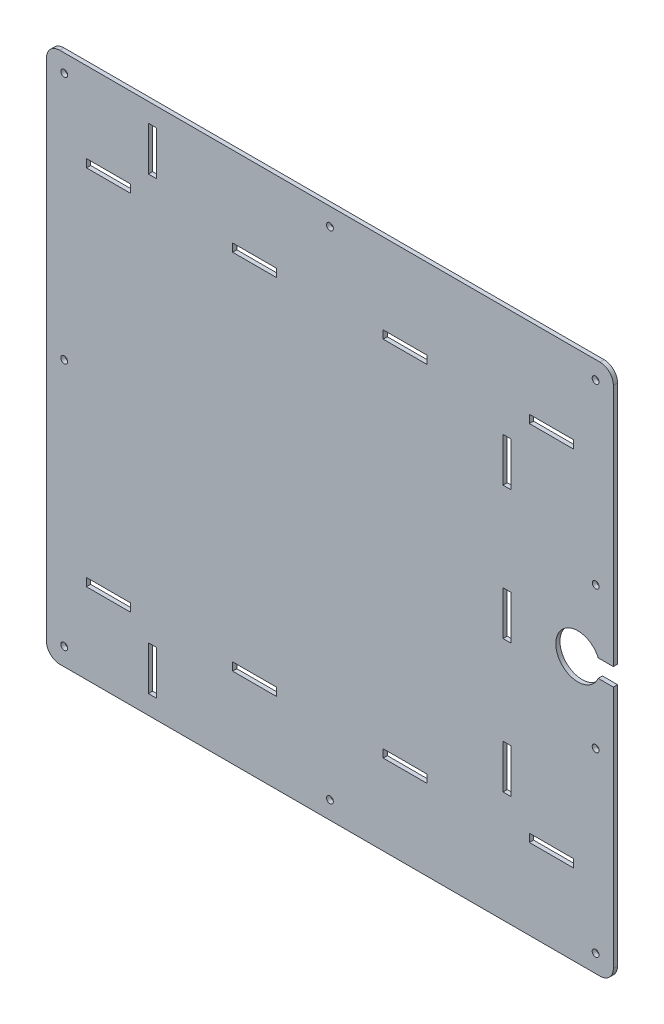
from build123d import *

# Parameters (mm, degrees)
BOSS_EXTRUDE1_DEPTH                   = 3
F_10_0_1935_DIAMETER_HOLE2_AT_2_COUNT = 2
F_10_0_1935_DIAMETER_HOLE2_AT_2_PITCH = 260.668884466
F_10_0_1935_DIAMETER_HOLE1_D          = 4.9149
F_10_0_1935_DIAMETER_HOLE1_DEPTH      = 76.2
F_10_0_1935_DIAMETER_HOLE1_TIP        = 1.476584928
SKETCH9_W                             = 31.5468
SKETCH9_H                             = 5.7658
SKETCH9_W_2                           = 5.7658
SKETCH9_H_2                           = 31.5468
CUT_EXTRUDE1_DEPTH                    = 4


with BuildPart() as part:
    # Sketch1 → Boss-Extrude1 (new body)
    with BuildSketch(Plane.XY):
        with BuildLine():
            Line((-135.866260139, -66.675), (-135.866260139, -314.579))
            Line((-135.866260139, -314.579), (-135.866260139, -371.729))
            ThreePointArc((-135.866260139, -371.729), (-133.07645223, -378.464192091), (-126.341260139, -381.254))
            Line((-126.341260139, -381.254), (261.008739861, -381.254))
            ThreePointArc((261.008739861, -381.254), (267.743931952, -378.464192091), (270.533739861, -371.729))
            Line((270.533739861, -371.729), (270.533739861, -298.704))
            Line((270.533739861, -298.704), (270.533739861, -196.977))
            Line((270.533739861, -196.977), (259.683417693, -196.977))
            ThreePointArc((259.683417693, -196.977), (229.258739861, -190.627), (259.683417693, -184.277))
            Line((259.683417693, -184.277), (270.533739861, -184.277))
            Line((270.533739861, -184.277), (270.533739861, -82.55))
            Line((270.533739861, -82.55), (270.533739861, -9.525))
            ThreePointArc((270.533739861, -9.525), (267.743931952, -2.789807909), (261.008739861, 0))
            Line((261.008739861, 0), (-126.341260139, 0))
            ThreePointArc((-126.341260139, 0), (-133.07645223, -2.789807909), (-135.866260139, -9.525))
            Line((-135.866260139, -9.525), (-135.866260139, -66.675))
        make_face()
    extrude(amount=BOSS_EXTRUDE1_DEPTH)

    # Sketch2 → #10 (0.1935) Diameter Hole3 (revolve, cut)
    with BuildSketch(Plane(origin=(-123.166260139, -12.7, 3), x_dir=(0, -1, 0), z_dir=(1, 0, 0))):
        Polygon((0, 0), (0, 77.676584928), (2.45745, 76.2), (2.45745, 0), align=None)
    f_10_0_1935_diameter_hole3 = revolve(axis=Axis((-123.166260139, -12.7, 9.35), (0, 0, -1)), mode=Mode.SUBTRACT)

    # Sketch7 → #10 (0.1935) Diameter Hole2 (revolve, cut)
    with BuildSketch(Plane(origin=(67.333739861, -12.7, 0), x_dir=(0, 1, 0), z_dir=(1, 0, 0))):
        Polygon((0, 0), (0, 77.676584928), (2.45745, 76.2), (2.45745, 0), align=None)
    f_10_0_1935_diameter_hole2 = revolve(axis=Axis((67.333739861, -12.7, -6.35), (0, 0, 1)), mode=Mode.SUBTRACT)

    # #10 (0.1935) Diameter Hole2 at 2: #10 (0.1935) Diameter Hole2 ×2
    with Locations(*[Vector(-0.730812196, -0.682578591, 0) * (i * F_10_0_1935_DIAMETER_HOLE2_AT_2_PITCH) for i in range(1, F_10_0_1935_DIAMETER_HOLE2_AT_2_COUNT)]):
        add(f_10_0_1935_diameter_hole2, mode=Mode.SUBTRACT)

    # Mirror1: #10 (0.1935) Diameter Hole3 across plane
    add(f_10_0_1935_diameter_hole3.mirror(Plane.ZY.offset(-67.333739861)), mode=Mode.SUBTRACT)

    # Mirror2: #10 (0.1935) Diameter Hole3, #10 (0.1935) Diameter Hole2 across plane
    add(f_10_0_1935_diameter_hole3.mirror(Plane.ZX.offset(-190.627)), mode=Mode.SUBTRACT)
    add(f_10_0_1935_diameter_hole2.mirror(Plane.ZX.offset(-190.627)), mode=Mode.SUBTRACT)

    # Mirror2 copy 1 sketch → Mirror2 copy 1 (revolve, cut)
    with BuildSketch(Plane(origin=(257.833739861, -368.554, 3), x_dir=(0, 1, 0), z_dir=(-1, 0, 0))):
        Polygon((0, 0), (0, 77.676584928), (2.45745, 76.2), (2.45745, 0), align=None)
    revolve(axis=Axis((257.833739861, -368.554, 9.35), (0, 0, -1)), mode=Mode.SUBTRACT)

    # Mirror2 copy 2 sketch → Mirror2 copy 2 (revolve, cut)
    with BuildSketch(Plane(origin=(-123.166260139, -190.627, 0), x_dir=(0, -1, 0), z_dir=(1, 0, 0))):
        Polygon((0, 0), (0, -77.676584928), (2.45745, -76.2), (2.45745, 0), align=None)
    revolve(axis=Axis((-123.166260139, -190.627, -6.35), (0, 0, -1)), mode=Mode.SUBTRACT)

    # #10 (0.1935) Diameter Hole1
    with Locations(Plane(origin=(257.833739861, -241.426988864, 0), x_dir=(-1, 0, 0), z_dir=(0, 0, -1))):
        with Locations((0, 0), (-0.067272713, 101.599977728)):
            Hole(F_10_0_1935_DIAMETER_HOLE1_D / 2, depth=F_10_0_1935_DIAMETER_HOLE1_DEPTH)
            with Locations((0, 0, -(F_10_0_1935_DIAMETER_HOLE1_DEPTH + F_10_0_1935_DIAMETER_HOLE1_TIP / 2))):  # 118° drill point
                Cone(0, F_10_0_1935_DIAMETER_HOLE1_D / 2, F_10_0_1935_DIAMETER_HOLE1_TIP, mode=Mode.SUBTRACT)

    # Sketch9 → Cut-Extrude1 (cut, through all)
    with BuildSketch(Plane(origin=(0, 0, 0), x_dir=(-1, 0, 0), z_dir=(0, 0, -1))):
        with Locations((-121.308739861, -320.675)):
            Rectangle(SKETCH9_W, SKETCH9_H)
        with Locations((-226.083739861, -320.675)):
            Rectangle(SKETCH9_W, SKETCH9_H)
        with Locations((-194.333739861, -285.877)):
            Rectangle(SKETCH9_W_2, SKETCH9_H_2)
        with Locations((-194.333739861, -190.627)):
            Rectangle(SKETCH9_W_2, SKETCH9_H_2)
        with Locations((-194.333739861, -95.377)):
            Rectangle(SKETCH9_W_2, SKETCH9_H_2)
        with Locations((-226.083739861, -60.579)):
            Rectangle(SKETCH9_W, SKETCH9_H)
        with Locations((-121.308739861, -60.579)):
            Rectangle(SKETCH9_W, SKETCH9_H)
        with Locations((-13.358739861, -60.579)):
            Rectangle(SKETCH9_W, SKETCH9_H)
        with Locations((91.416260139, -60.579)):
            Rectangle(SKETCH9_W, SKETCH9_H)
        with Locations((59.932960139, -351.90938)):
            Rectangle(SKETCH9_W_2, SKETCH9_H_2)
        with Locations((59.932960139, -29.34462)):
            Rectangle(SKETCH9_W_2, SKETCH9_H_2)
        with Locations((91.416260139, -320.675)):
            Rectangle(SKETCH9_W, SKETCH9_H)
        with Locations((-13.358739861, -320.675)):
            Rectangle(SKETCH9_W, SKETCH9_H)
    extrude(amount=-CUT_EXTRUDE1_DEPTH, mode=Mode.SUBTRACT)


solid = part.part
